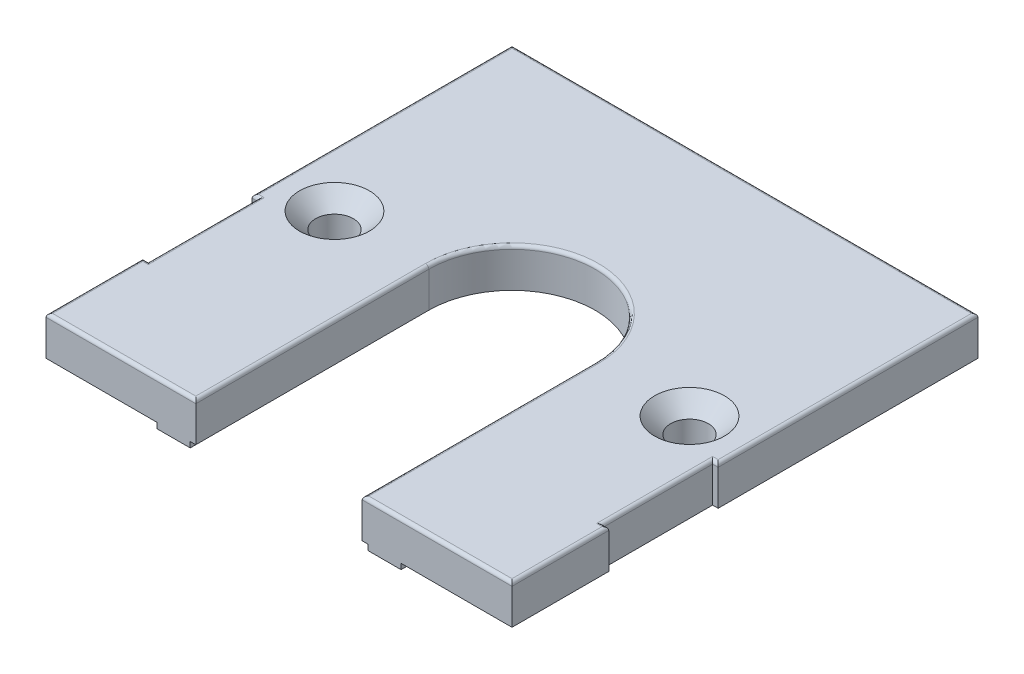
from build123d import *

# Parameters (mm, degrees)
SALIENTE_EXTRUIR1_DEPTH                              = 3.5
AVELLANADO_PARA_TORNILLO_CON_CABEZA_PLAN_D           = 3.4
AVELLANADO_PARA_TORNILLO_CON_CABEZA_PLAN_CSINK_D     = 6.3
AVELLANADO_PARA_TORNILLO_CON_CABEZA_PLAN_CSINK_ANGLE = 90
REDONDEO1_R                                          = 0.3
CROQUIS4_W                                           = 3
CROQUIS4_H                                           = 42
SALIENTE_EXTRUIR2_DEPTH                              = 0.5
CORTAR_EXTRUIR1_DEPTH                                = 2


with BuildPart() as part:
    # Croquis1 → Saliente-Extruir1 (new body)
    with BuildSketch(Plane(origin=(0, 0, 0), x_dir=(1, 0, 0), z_dir=(0, 1, 0))):
        with BuildLine():
            Line((-7.5, 0), (-7.5, -21))
            Line((-7.5, -21), (-21, -21))
            Line((-21, -21), (-21, -12.28))
            Line((-21, -12.28), (-20.5, -12.28))
            Line((-20.5, -12.28), (-20.5, -2.42))
            Line((-20.5, -2.42), (-21, -2.42))
            Line((-21, -2.42), (-21, 21))
            Line((-21, 21), (21, 21))
            Line((21, 21), (21, -2.42))
            Line((21, -2.42), (20.5, -2.42))
            Line((20.5, -2.42), (20.5, -12.28))
            Line((20.5, -12.28), (21, -12.28))
            Line((21, -12.28), (21, -21))
            Line((21, -21), (7.5, -21))
            Line((7.5, -21), (7.5, 0))
            ThreePointArc((7.5, 0), (0, 7.5), (-7.5, 0))
        make_face()
    extrude(amount=-SALIENTE_EXTRUIR1_DEPTH)

    # Avellanado para tornillo con cabeza plana avellanada de M31 (through all)
    with Locations(Plane(origin=(0, 0, 0), x_dir=(1, 0, 0), z_dir=(0, 1, 0))):
        with Locations((-16, 0), (16, 0)):
            CounterSinkHole(AVELLANADO_PARA_TORNILLO_CON_CABEZA_PLAN_D / 2, AVELLANADO_PARA_TORNILLO_CON_CABEZA_PLAN_CSINK_D / 2, counter_sink_angle=AVELLANADO_PARA_TORNILLO_CON_CABEZA_PLAN_CSINK_ANGLE)

    # Redondeo1
    redondeo1_edges = [part.edges().sort_by_distance(p)[0] for p in [
        (14.25, 0, 21),
        (7.5, 0, 10.5),
        (0, 0, -7.5),
        (-7.5, 0, 10.5),
        (-14.25, 0, 21),
        (-21, 0, 16.64),
        (-20.75, 0, 12.28),
        (-20.5, 0, 7.35),
        (-20.75, 0, 2.42),
        (-21, 0, -9.29),
        (0, 0, -21),
        (21, 0, -9.29),
        (20.75, 0, 2.42),
        (20.5, 0, 7.35),
        (20.75, 0, 12.28),
        (21, 0, 16.64),
    ]]
    fillet(redondeo1_edges, radius=REDONDEO1_R)

    # Croquis4 → Saliente-Extruir2 (add)
    with BuildSketch(Plane.XZ.offset(3.5)):
        with Locations((9.5, 0)):
            Rectangle(CROQUIS4_W, CROQUIS4_H)
        with Locations((-9.5, 0)):
            Rectangle(CROQUIS4_W, CROQUIS4_H)
    extrude(amount=SALIENTE_EXTRUIR2_DEPTH)

    # Croquis5 → Cortar-Extruir1 (cut)
    with BuildSketch(Plane.XZ.offset(3.5)):
        with BuildLine():
            Line((-5.5, -9.7), (5.5, -9.7))
            ThreePointArc((5.5, -9.7), (7, -11.2), (5.5, -12.7))
            Line((5.5, -12.7), (-5.5, -12.7))
            ThreePointArc((-5.5, -12.7), (-7, -11.2), (-5.5, -9.7))
        make_face()
    extrude(amount=-CORTAR_EXTRUIR1_DEPTH, mode=Mode.SUBTRACT)


solid = part.part
